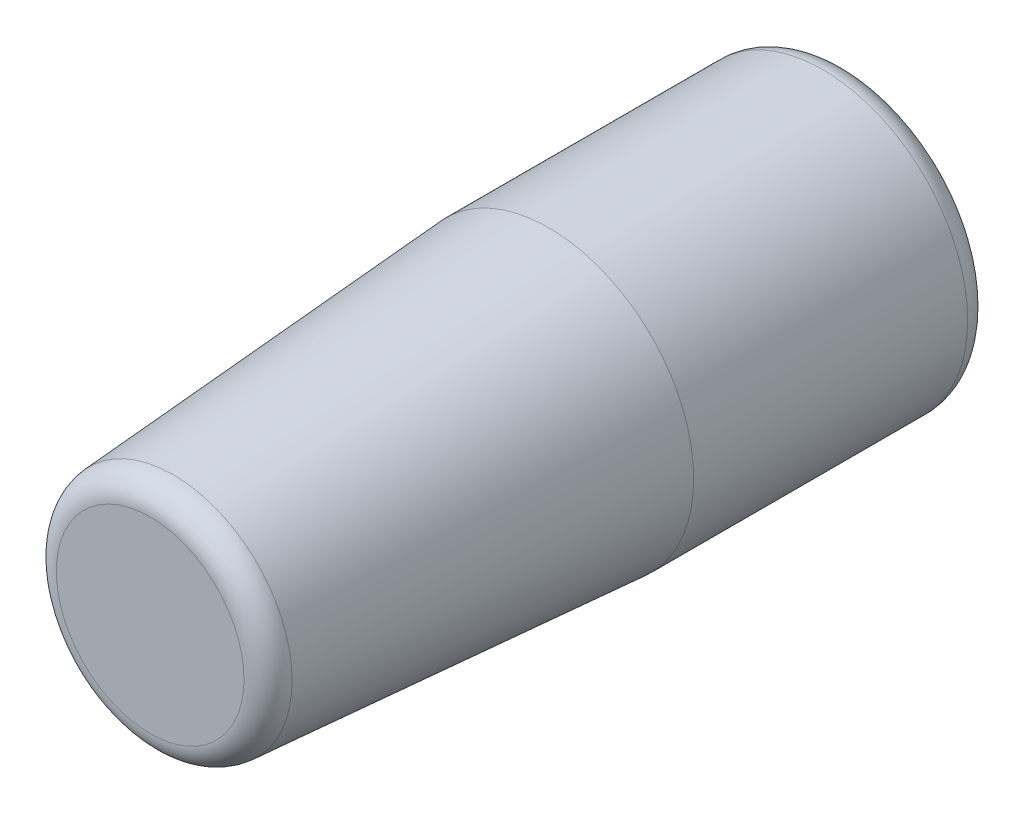
from build123d import *

# Parameters (mm, degrees)
SKETCH1_R           = 73.914
BOSS_EXTRUDE1_DEPTH = 152.4
SKETCH2_R           = 73.914
BOSS_EXTRUDE2_DEPTH = 203.2
BOSS_EXTRUDE2_TAPER = 4
FILLET1_R           = 12.7


with BuildPart() as part:
    # Sketch1 → Boss-Extrude1 (new body)
    with BuildSketch(Plane.XY):
        Circle(SKETCH1_R)
    extrude(amount=BOSS_EXTRUDE1_DEPTH)

    # Sketch2 → Boss-Extrude2 (add)
    with BuildSketch(Plane.XY.offset(152.4)):
        Circle(SKETCH2_R)
    extrude(amount=BOSS_EXTRUDE2_DEPTH, taper=BOSS_EXTRUDE2_TAPER)

    # Fillet1
    fillet1_edges = [part.edges().sort_by_distance(p)[0] for p in [
        (-73.914, 0, 0),
        (-59.704871813, 0, 355.6),
    ]]
    fillet(fillet1_edges, radius=FILLET1_R)


solid = part.part
